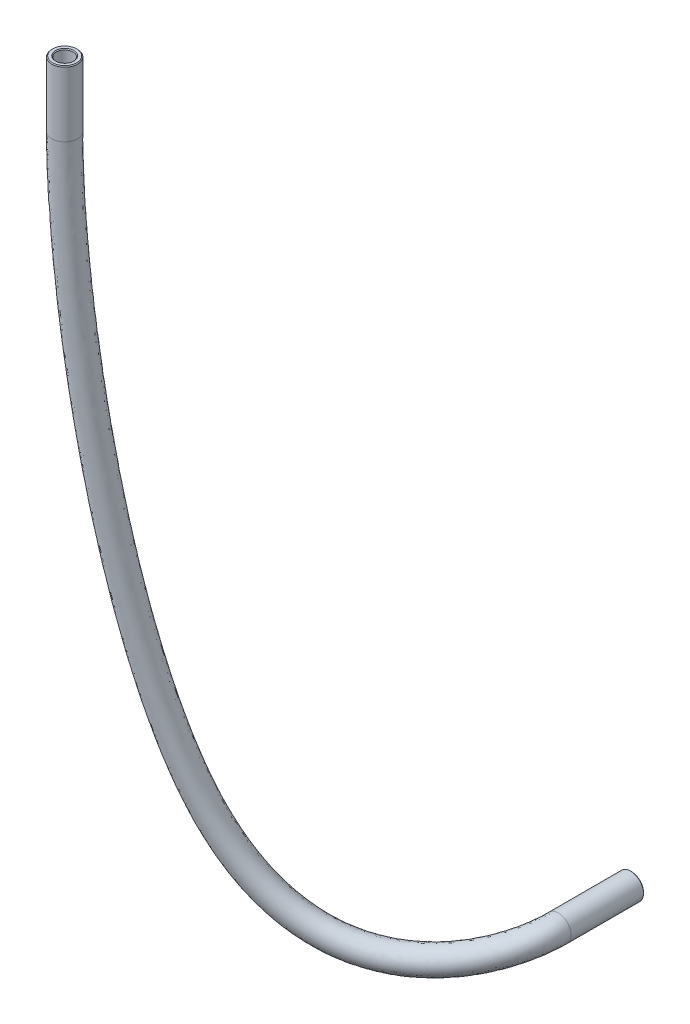
from build123d import *

# Parameters (mm, degrees)
SKETCH1_R     = 2
SKETCH1_R_2   = 1.3
CHAMFER1_SIZE = 0.127


with BuildPart() as part:
    # Sweep1: sweep along a curve in space
    with BuildLine() as sweep1_path:
        Line((-105.398836904, -220.793822562, -61.0875), (-105.398836904, -220.793822562, -49.6875))
        add(Edge.make_bspline(
            [(-105.398836904, -220.793822562, -49.6875), (-105.398836904, -220.793822562, -39.926543645), (-140.244879709, -242.363029084, -25.062484458), (-150.085279081, -143.096824625, -17.525), (-150.085279081, -119.682256564, -17.525)],
            knots=[0, 0, 0, 0, 0.5467542, 1, 1, 1, 1], degree=3))
        Line((-150.085279081, -119.682256564, -17.525), (-150.085279081, -109.482256564, -17.525))
    # Sketch1 → Sweep1 (sweep)
    with BuildSketch(Plane.XZ.offset(117.582256564)):
        with Locations((-150.085279081, -17.525)):
            Circle(SKETCH1_R)
        with Locations((-150.085279081, -17.525)):
            Circle(SKETCH1_R_2, mode=Mode.SUBTRACT)
    sweep(path=sweep1_path.line)

    # Chamfer1
    chamfer1_edges = [part.edges().sort_by_distance(p)[0] for p in [
        (-105.848067378, -222.013737305, -61.0875),
        (-106.08996071, -222.670614475, -61.0875),
        (-151.385279081, -109.482256564, -17.525),
        (-152.085279081, -109.482256564, -17.525),
    ]]
    chamfer(chamfer1_edges, length=CHAMFER1_SIZE)


solid = part.part
